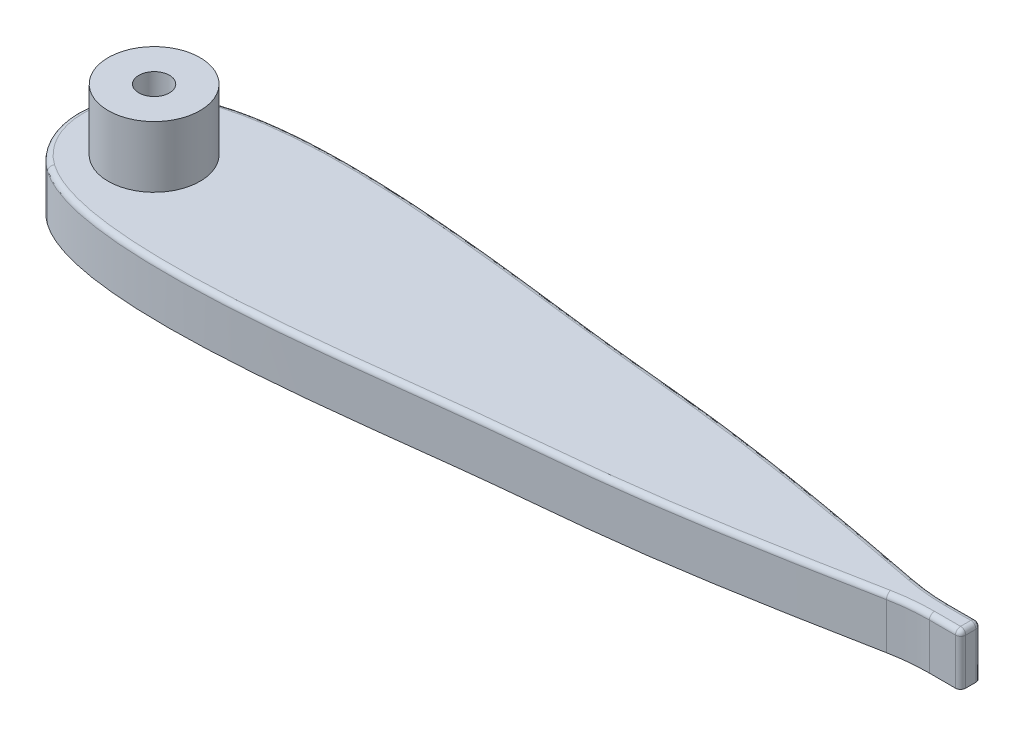
from build123d import *

# Parameters (mm, degrees)
BOSS_EXTRUDE2_DEPTH = 5
FILLET1_R           = 20
FILLET2_R           = 0.5
FILLET3_R           = 0.5
BOSS_EXTRUDE3_START = -5
SKETCH3_R           = 4.5
BOSS_EXTRUDE3_DEPTH = 6
SKETCH4_R           = 1.5
CUT_EXTRUDE2_DEPTH  = 3
SKETCH5_R           = 1
CUT_EXTRUDE3_DEPTH  = 12
SKETCH6_R           = 2.5
CUT_EXTRUDE4_DEPTH  = 6


with BuildPart() as part:
    # Sketch1 → Boss-Extrude2 (new body)
    with BuildSketch(Plane(origin=(0, 0, 0), x_dir=(1, 0, 0), z_dir=(0, 1, 0))):
        with BuildLine():
            add(Edge.make_bspline(
                [(75, 1), (51.048339176, 5.728731358), (45.1182825, 4.898127099), (3.12007861, 11.367310368), (-4.316655623, 6.133227881)],
                knots=[1, 1, 1, 1, 1.470494553, 1.969101002, 1.969101002, 1.969101002, 1.969101002], degree=3))
            ThreePointArc((-4.316655623, 6.133227881), (-7.5, 0), (-4.316655623, -6.133227881))
            add(Edge.make_bspline(
                [(-4.316655623, -6.133227881), (3.12007861, -11.367310368), (45.1182825, -4.898127099), (51.048339176, -5.728731358), (75, -1)],
                knots=[0, 0, 0, 0, 0.498606449, 0.969101002, 0.969101002, 0.969101002, 0.969101002], degree=3))
            Line((75, -1), (80, -1))
            Line((80, -1), (80, 1))
            Line((80, 1), (75, 1))
        make_face()
    extrude(amount=BOSS_EXTRUDE2_DEPTH)

    # Fillet1
    fillet1_edges = [part.edges().sort_by_distance(p)[0] for p in [
        (75, 2.5, -1),
        (75, 2.5, 1),
    ]]
    fillet(fillet1_edges, radius=FILLET1_R)

    # Fillet2
    fillet2_edges = [part.edges().sort_by_distance(p)[0] for p in [
        (80, 2.5, -1),
        (80, 2.5, 1),
    ]]
    fillet(fillet2_edges, radius=FILLET2_R)

    # Fillet3
    fillet3_edges = [part.edges().sort_by_distance(p)[0] for p in [
        (34.320045322, 5, 6.936969607),
        (78.222297367, 5, -1),
        (78.222297367, 5, 1),
        (75.020078886, 5, -1.092809371),
        (75.020078886, 5, 1.092809371),
        (80, 5, 0),
        (34.320045325, 5, -6.936969606),
        (79.853553391, 5, -0.853553391),
        (79.853553391, 5, 0.853553391),
        (-7.5, 5, 0),
    ]]
    fillet(fillet3_edges, radius=FILLET3_R)

    # Sketch3 → Boss-Extrude3 (add)
    with BuildSketch(Plane.XZ.offset(BOSS_EXTRUDE3_START)):
        Circle(SKETCH3_R)
    extrude(amount=-BOSS_EXTRUDE3_DEPTH)

    # Sketch4 → Cut-Extrude2 (cut)
    with BuildSketch(Plane(origin=(0, 11, 0), x_dir=(1, 0, 0), z_dir=(0, 1, 0))):
        Circle(SKETCH4_R)
    extrude(amount=-CUT_EXTRUDE2_DEPTH, mode=Mode.SUBTRACT)

    # Sketch5 → Cut-Extrude3 (cut, through all)
    with BuildSketch(Plane.XZ):
        Circle(SKETCH5_R)
    extrude(amount=-CUT_EXTRUDE3_DEPTH, mode=Mode.SUBTRACT)

    # Sketch6 → Cut-Extrude4 (cut)
    with BuildSketch(Plane.XZ):
        Circle(SKETCH6_R)
    extrude(amount=-CUT_EXTRUDE4_DEPTH, mode=Mode.SUBTRACT)


solid = part.part
